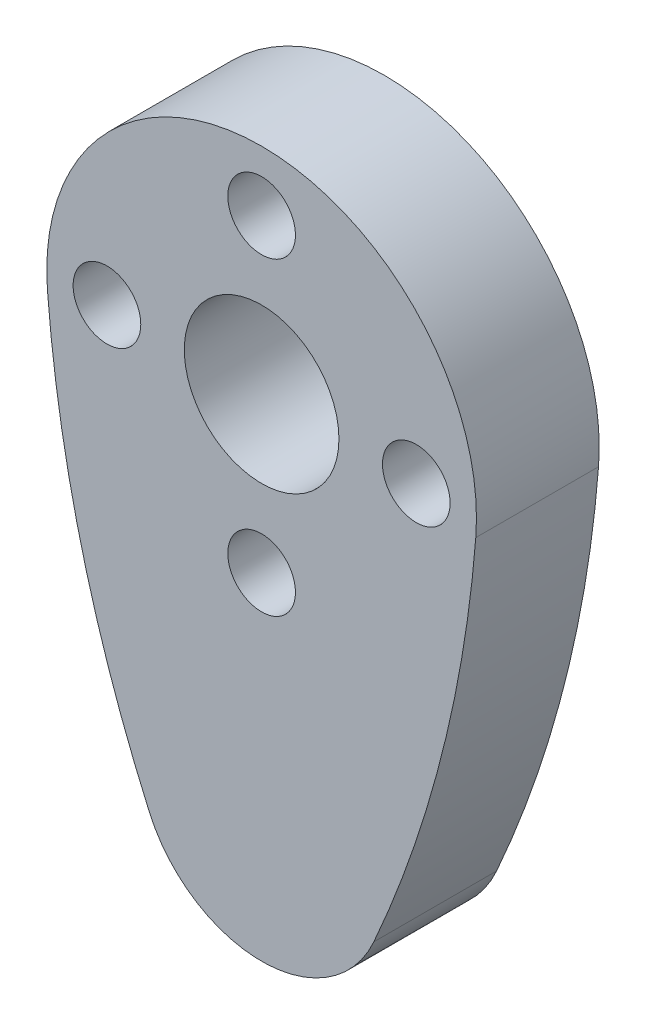
from build123d import *

# Parameters (mm, degrees)
SKETCH1_R           = 4
SKETCH1_R_2         = 1.75
BOSS_EXTRUDE1_DEPTH = 6.35


with BuildPart() as part:
    # Sketch1 → Boss-Extrude1 (new body)
    with BuildSketch(Plane.XY):
        with BuildLine():
            ThreePointArc((-11.077287152, -0.883948864), (0, 11.1125), (11.077287152, -0.883948864))
            ThreePointArc((11.077287152, -0.883948864), (9.32030962, -11.480690637), (5.802388508, -21.6296875))
            ThreePointArc((5.802388508, -21.6296875), (3.459876036, -24.374636871), (0, -25.4))
            ThreePointArc((0, -25.4), (-3.459876036, -24.374636871), (-5.802388508, -21.6296875))
            ThreePointArc((-5.802388508, -21.6296875), (-9.32030962, -11.480690637), (-11.077287152, -0.883948864))
        make_face()
        Circle(SKETCH1_R, mode=Mode.SUBTRACT)
        with Locations((8, 0)):
            Circle(SKETCH1_R_2, mode=Mode.SUBTRACT)
        with Locations((0, -8)):
            Circle(SKETCH1_R_2, mode=Mode.SUBTRACT)
        with Locations((-8, 0)):
            Circle(SKETCH1_R_2, mode=Mode.SUBTRACT)
        with Locations((0, 8)):
            Circle(SKETCH1_R_2, mode=Mode.SUBTRACT)
    extrude(amount=BOSS_EXTRUDE1_DEPTH)


solid = part.part
